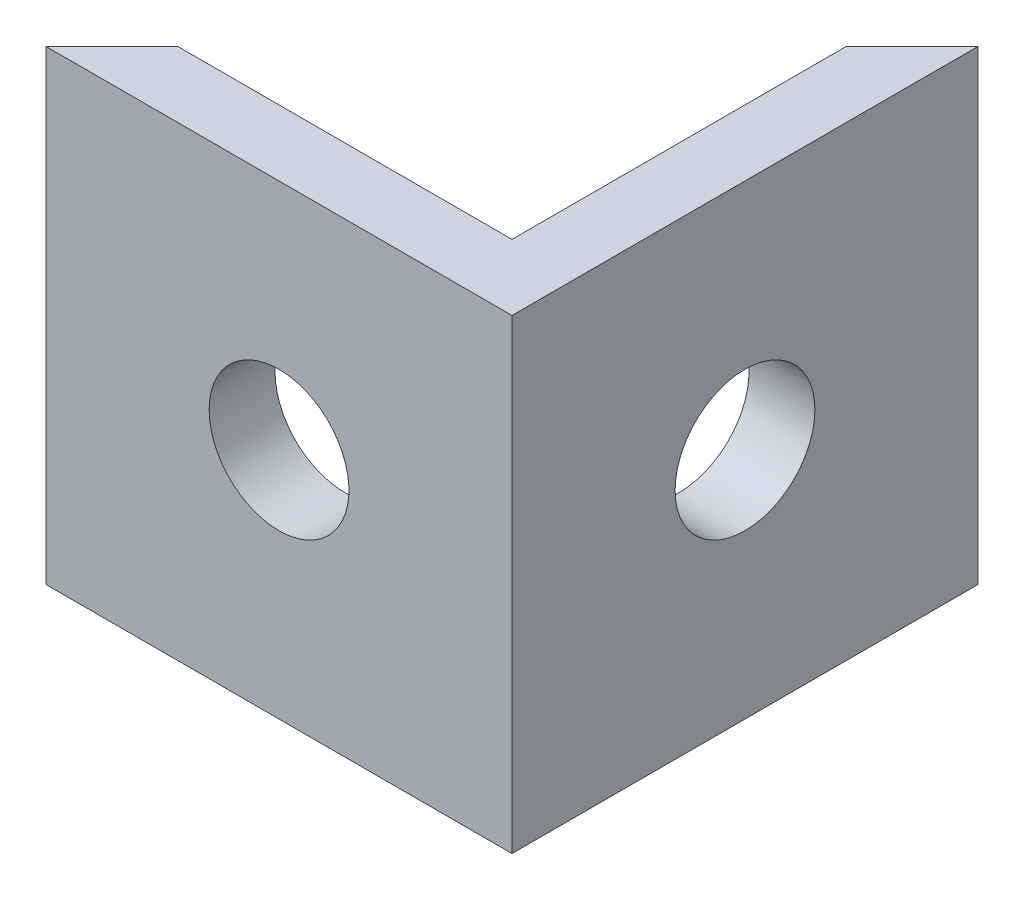
from build123d import *

# Parameters (mm, degrees)
IZIM1_W                     = 10
IZIM1_H                     = 10
Y_KSEKLIK_EKSTR_ZYON1_DEPTH = 10
KES_EKSTR_ZYON1_DEPTH       = 10
IZIM3_W                     = 9.22702718
IZIM3_H                     = 8.892036637
KES_EKSTR_ZYON2_DEPTH       = 10
KES_EKSTR_ZYON3_DEPTH       = 10
IZIM6_R                     = 1.5
KES_EKSTR_ZYON4_DEPTH       = 10


with BuildPart() as part:
    # Çizim1 → Yükseklik-Ekstrüzyon1 (new body)
    with BuildSketch(Plane(origin=(0, 0, 0), x_dir=(1, 0, 0), z_dir=(0, 1, 0))):
        with Locations((-23.640485452, -27.285638146)):
            Rectangle(IZIM1_W, IZIM1_H)
    extrude(amount=Y_KSEKLIK_EKSTR_ZYON1_DEPTH)

    # Çizim2 → Kes-Ekstrüzyon1 (cut)
    with BuildSketch(Plane(origin=(0, 10, 0), x_dir=(1, 0, 0), z_dir=(0, 1, 0))):
        Polygon((-28.640485452, -22.285638146), (-18.640485452, -22.285638146), (-28.640485452, -32.285638146), align=None)
    extrude(amount=-KES_EKSTR_ZYON1_DEPTH, mode=Mode.SUBTRACT)

    # Çizim3 → Kes-Ekstrüzyon2 (cut)
    with BuildSketch(Plane(origin=(0, 10, 0), x_dir=(1, 0, 0), z_dir=(0, 1, 0))):
        with Locations((-24.668212605, -26.425406266)):
            Rectangle(IZIM3_W, IZIM3_H)
    extrude(amount=-KES_EKSTR_ZYON2_DEPTH, mode=Mode.SUBTRACT)

    # Çizim5 → Kes-Ekstrüzyon3 (cut)
    with BuildSketch(Plane.ZY.offset(20.054699015)):
        with BuildLine():
            ThreePointArc((28.785638146, 5), (27.970743901, 6.334402527), (26.411464673, 6.218942467))
            Line((26.411464673, 6.218942467), (28.15981162, 3.781057533))
            ThreePointArc((28.15981162, 3.781057533), (28.620040674, 4.314894245), (28.785638146, 5))
        make_face()
        with BuildLine():
            Line((28.15981162, 3.781057533), (26.411464673, 6.218942467))
            ThreePointArc((26.411464673, 6.218942467), (26.066695679, 4.125826527), (28.15981162, 3.781057533))
        make_face()
    extrude(amount=-KES_EKSTR_ZYON3_DEPTH, mode=Mode.SUBTRACT)

    # Çizim6 → Kes-Ekstrüzyon4 (cut)
    with BuildSketch(Plane(origin=(0, 0, 30.871424584), x_dir=(-1, 0, 0), z_dir=(0, 0, -1))):
        with Locations((23.640485452, 5)):
            Circle(IZIM6_R)
    extrude(amount=-KES_EKSTR_ZYON4_DEPTH, mode=Mode.SUBTRACT)


solid = part.part
